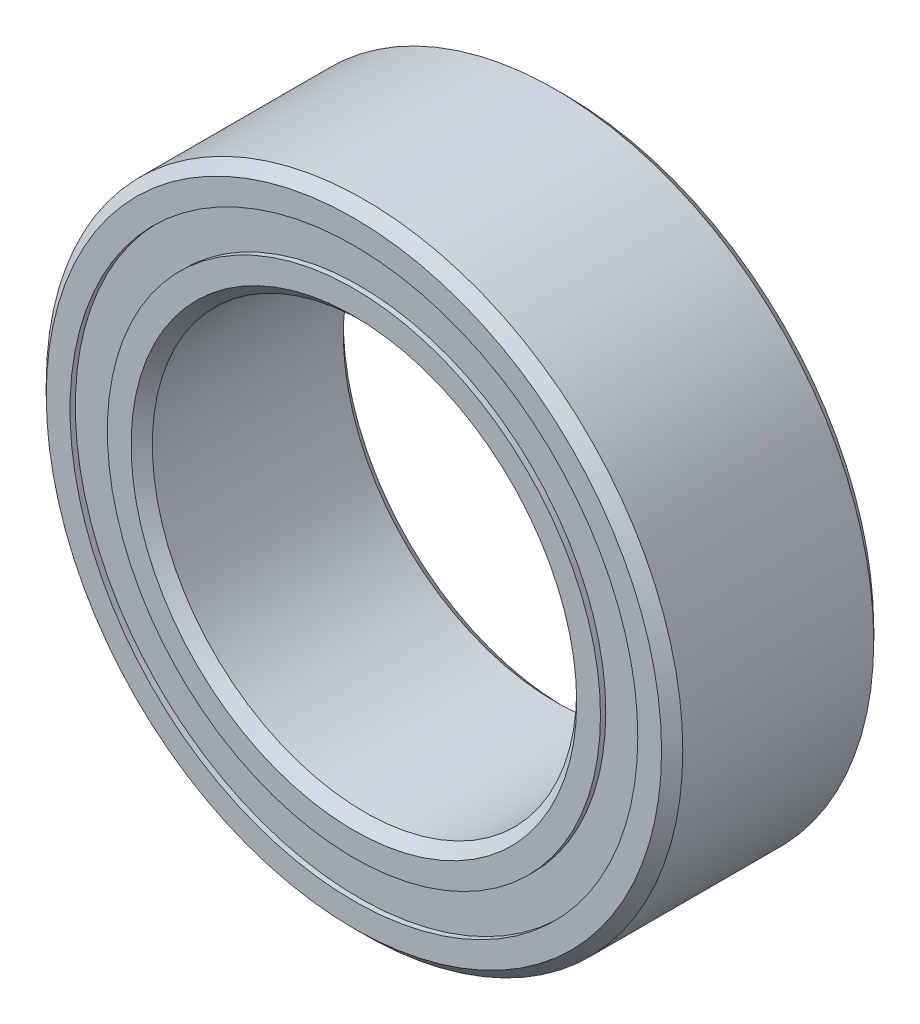
from build123d import *

# Parameters (mm, degrees)
CIRPATTERN1_COUNT = 12
SKETCH5_W         = 0.749364756
SKETCH5_H         = 0.558241758


with BuildPart() as part:
    # Sketch1 → Revolve1 (revolve)
    with BuildSketch(Plane(origin=(0, 0, 0), x_dir=(0, 0, -1), z_dir=(1, 0, 0))):
        with BuildLine():
            Line((1.42875, 4.7625), (-1.42875, 4.7625))
            Line((-1.42875, 4.7625), (-1.5875, 4.60375))
            Line((-1.5875, 4.60375), (-1.5875, 4.247870879))
            Line((-1.5875, 4.247870879), (-0.705555556, 4.247870879))
            ThreePointArc((-0.705555556, 4.247870879), (0, 4.727510244), (0.705555556, 4.247870879))
            Line((0.705555556, 4.247870879), (1.5875, 4.247870879))
            Line((1.5875, 4.247870879), (1.5875, 4.60375))
            Line((1.5875, 4.60375), (1.42875, 4.7625))
        make_face()
    revolve(axis=Axis((0, 0, 1.5875), (0, 0, -1)))


with BuildPart() as body_2:
    # Sketch3 → Revolve3 (revolve)
    with BuildSketch(Plane(origin=(0, 0, 0), x_dir=(0, 0, -1), z_dir=(1, 0, 0))):
        with BuildLine():
            Line((-0.705555556, 3.689629121), (-1.5875, 3.689629121))
            Line((-1.5875, 3.689629121), (-1.5875, 3.33375))
            Line((-1.5875, 3.33375), (-1.42875, 3.175))
            Line((-1.42875, 3.175), (1.42875, 3.175))
            Line((1.42875, 3.175), (1.5875, 3.33375))
            Line((1.5875, 3.33375), (1.5875, 3.689629121))
            Line((1.5875, 3.689629121), (0.705555556, 3.689629121))
            ThreePointArc((0.705555556, 3.689629121), (0, 3.209989756), (-0.705555556, 3.689629121))
        make_face()
    revolve(axis=Axis((0, 0, 1.5875), (0, 0, -1)))


with BuildPart() as body_3:
    # Sketch4 → Revolve4 (revolve)
    with BuildSketch(Plane(origin=(0, 0, 0), x_dir=(0, 0, -1), z_dir=(1, 0, 0))):
        with BuildLine():
            Line((-0.758760244, 3.96875), (0.758760244, 3.96875))
            ThreePointArc((0.758760244, 3.96875), (0, 4.727510244), (-0.758760244, 3.96875))
        make_face()
    revolve(axis=Axis((0, 3.96875, 0.758760244), (0, 0, -1)))


with BuildPart() as cirpattern1_1:
    # CirPattern1: pattern copy
    add(body_3.part.rotate(Axis((0, 0, -1.5875), (0, 0, 1)), 1 * 360 / CIRPATTERN1_COUNT))


with BuildPart() as cirpattern1_2:
    # CirPattern1: pattern copy
    add(body_3.part.rotate(Axis((0, 0, -1.5875), (0, 0, 1)), 2 * 360 / CIRPATTERN1_COUNT))


with BuildPart() as cirpattern1_3:
    # CirPattern1: pattern copy
    add(body_3.part.rotate(Axis((0, 0, -1.5875), (0, 0, 1)), 3 * 360 / CIRPATTERN1_COUNT))


with BuildPart() as cirpattern1_4:
    # CirPattern1: pattern copy
    add(body_3.part.rotate(Axis((0, 0, -1.5875), (0, 0, 1)), 4 * 360 / CIRPATTERN1_COUNT))


with BuildPart() as cirpattern1_5:
    # CirPattern1: pattern copy
    add(body_3.part.rotate(Axis((0, 0, -1.5875), (0, 0, 1)), 5 * 360 / CIRPATTERN1_COUNT))


with BuildPart() as cirpattern1_6:
    # CirPattern1: pattern copy
    add(body_3.part.rotate(Axis((0, 0, -1.5875), (0, 0, 1)), 6 * 360 / CIRPATTERN1_COUNT))


with BuildPart() as cirpattern1_7:
    # CirPattern1: pattern copy
    add(body_3.part.rotate(Axis((0, 0, -1.5875), (0, 0, 1)), 7 * 360 / CIRPATTERN1_COUNT))


with BuildPart() as cirpattern1_8:
    # CirPattern1: pattern copy
    add(body_3.part.rotate(Axis((0, 0, -1.5875), (0, 0, 1)), 8 * 360 / CIRPATTERN1_COUNT))


with BuildPart() as cirpattern1_9:
    # CirPattern1: pattern copy
    add(body_3.part.rotate(Axis((0, 0, -1.5875), (0, 0, 1)), 9 * 360 / CIRPATTERN1_COUNT))


with BuildPart() as cirpattern1_10:
    # CirPattern1: pattern copy
    add(body_3.part.rotate(Axis((0, 0, -1.5875), (0, 0, 1)), 10 * 360 / CIRPATTERN1_COUNT))


with BuildPart() as cirpattern1_11:
    # CirPattern1: pattern copy
    add(body_3.part.rotate(Axis((0, 0, -1.5875), (0, 0, 1)), 11 * 360 / CIRPATTERN1_COUNT))


with BuildPart() as body_15:
    # Sketch5 → Revolve5 (revolve)
    with BuildSketch(Plane(origin=(0, 0, 0), x_dir=(0, 0, -1), z_dir=(1, 0, 0))):
        with Locations((-1.133442622, 3.96875)):
            Rectangle(SKETCH5_W, SKETCH5_H)
        with Locations((1.133442622, 3.96875)):
            Rectangle(SKETCH5_W, SKETCH5_H)
    revolve(axis=Axis((0, 0, 1.5875), (0, 0, -1)))


solid = Compound([part.part, body_2.part, body_3.part, cirpattern1_1.part, cirpattern1_2.part, cirpattern1_3.part, cirpattern1_4.part, cirpattern1_5.part, cirpattern1_6.part, cirpattern1_7.part, cirpattern1_8.part, cirpattern1_9.part, cirpattern1_10.part, cirpattern1_11.part, body_15.part])
